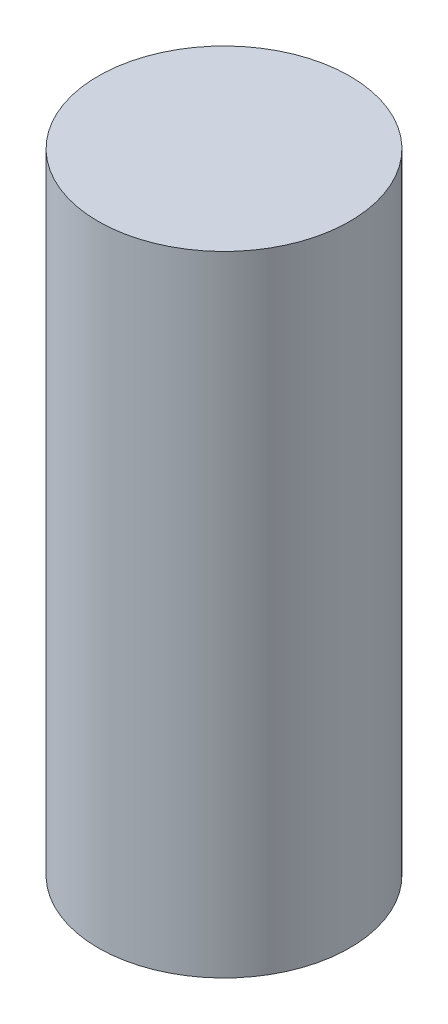
from build123d import *

# Parameters (mm, degrees)
SKETCH1_R           = 4
BOSS_EXTRUDE1_DEPTH = 20


with BuildPart() as part:
    # Sketch1 → Boss-Extrude1 (new body)
    with BuildSketch(Plane(origin=(0, 0, 0), x_dir=(1, 0, 0), z_dir=(0, 1, 0))):
        Circle(SKETCH1_R)
    extrude(amount=BOSS_EXTRUDE1_DEPTH)


solid = part.part
